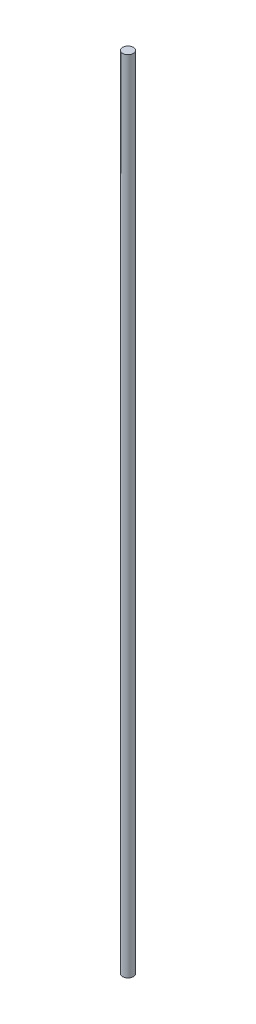
from build123d import *

# Parameters (mm, degrees)
SKETCH1_R           = 4
BOSS_EXTRUDE1_DEPTH = 600


with BuildPart() as part:
    # Sketch1 → Boss-Extrude1 (new body)
    with BuildSketch(Plane(origin=(0, 0, 0), x_dir=(1, 0, 0), z_dir=(0, 1, 0))):
        Circle(SKETCH1_R)
    extrude(amount=BOSS_EXTRUDE1_DEPTH)


solid = part.part
